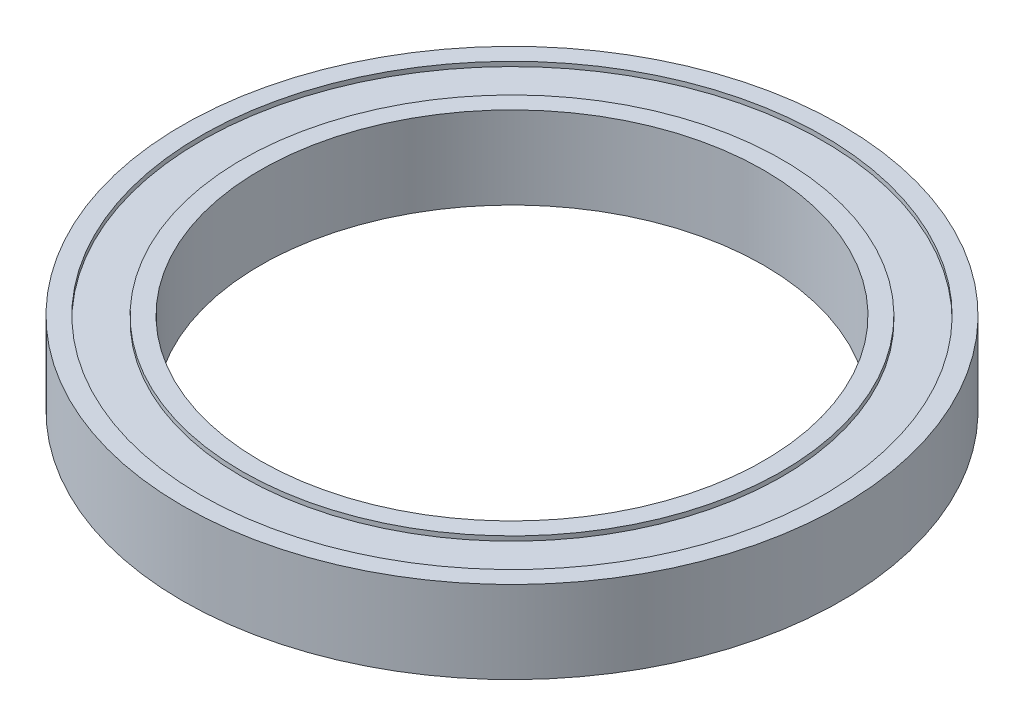
from build123d import *

# Parameters (mm, degrees)
SKETCH_1_R          = 36
SKETCH_1_R_2        = 27.5
EXTRUDE_1_DEPTH     = 4.5
SKETCH_3_R          = 34
SKETCH_3_R_2        = 29.5
CUT_EXTRUDE_1_DEPTH = 0.5


with BuildPart() as part:
    # 草图1 → 凸台-拉伸1 (new body, symmetric)
    with BuildSketch(Plane(origin=(0, 0, 0), x_dir=(1, 0, 0), z_dir=(0, 1, 0))):
        Circle(SKETCH_1_R)
        Circle(SKETCH_1_R_2, mode=Mode.SUBTRACT)
    extrude(amount=EXTRUDE_1_DEPTH, both=True)

    # 草图3 → 切除-拉伸1 (cut)
    with BuildSketch(Plane(origin=(0, 4.5, 0), x_dir=(1, 0, 0), z_dir=(0, 1, 0))):
        Circle(SKETCH_3_R)
        Circle(SKETCH_3_R_2, mode=Mode.SUBTRACT)
    cut_extrude_1 = extrude(amount=-CUT_EXTRUDE_1_DEPTH, mode=Mode.SUBTRACT)

    # 镜向1: 切除-拉伸1 across plane
    add(cut_extrude_1.mirror(Plane.ZX), mode=Mode.SUBTRACT)


solid = part.part
